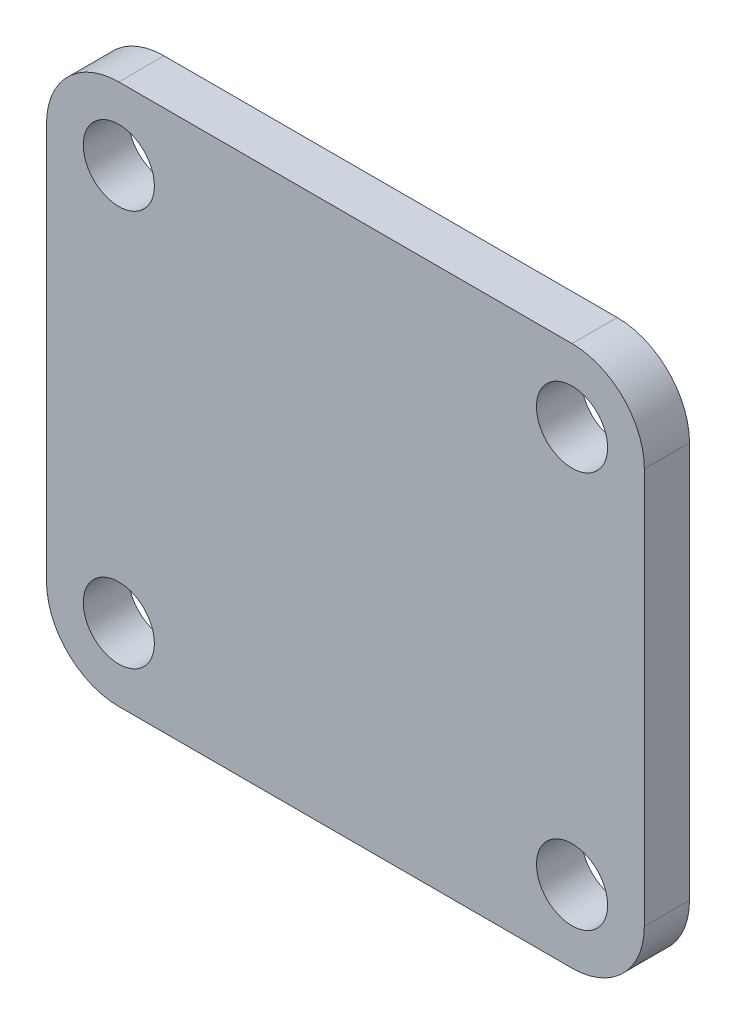
from build123d import *

# Parameters (mm, degrees)
BOSS_EXTRUDE1_DEPTH = 1.5875
SKETCH2_R           = 1.25
CUT_EXTRUDE1_DEPTH  = 2.5875


with BuildPart() as part:
    # Sketch1 → Boss-Extrude1 (new body)
    with BuildSketch(Plane.XY):
        with BuildLine():
            Line((7.96, -9.5), (-7.96, -9.5))
            ThreePointArc((-7.96, -9.5), (-9.756051224, -8.756051224), (-10.5, -6.96))
            Line((-10.5, -6.96), (-10.5, 6.96))
            ThreePointArc((-10.5, 6.96), (-9.756051224, 8.756051224), (-7.96, 9.5))
            Line((-7.96, 9.5), (7.96, 9.5))
            ThreePointArc((7.96, 9.5), (9.756051224, 8.756051224), (10.5, 6.96))
            Line((10.5, 6.96), (10.5, -6.96))
            ThreePointArc((10.5, -6.96), (9.756051224, -8.756051224), (7.96, -9.5))
        make_face()
    extrude(amount=BOSS_EXTRUDE1_DEPTH)

    # Sketch2 → Cut-Extrude1 (cut, through all)
    with BuildSketch(Plane.XY.offset(1.5875)):
        with Locations((-7.96, 6.96)):
            Circle(SKETCH2_R)
        with Locations((7.96, 6.96)):
            Circle(SKETCH2_R)
        with Locations((7.96, -6.96)):
            Circle(SKETCH2_R)
        with Locations((-7.96, -6.96)):
            Circle(SKETCH2_R)
    extrude(amount=-CUT_EXTRUDE1_DEPTH, mode=Mode.SUBTRACT)


solid = part.part
